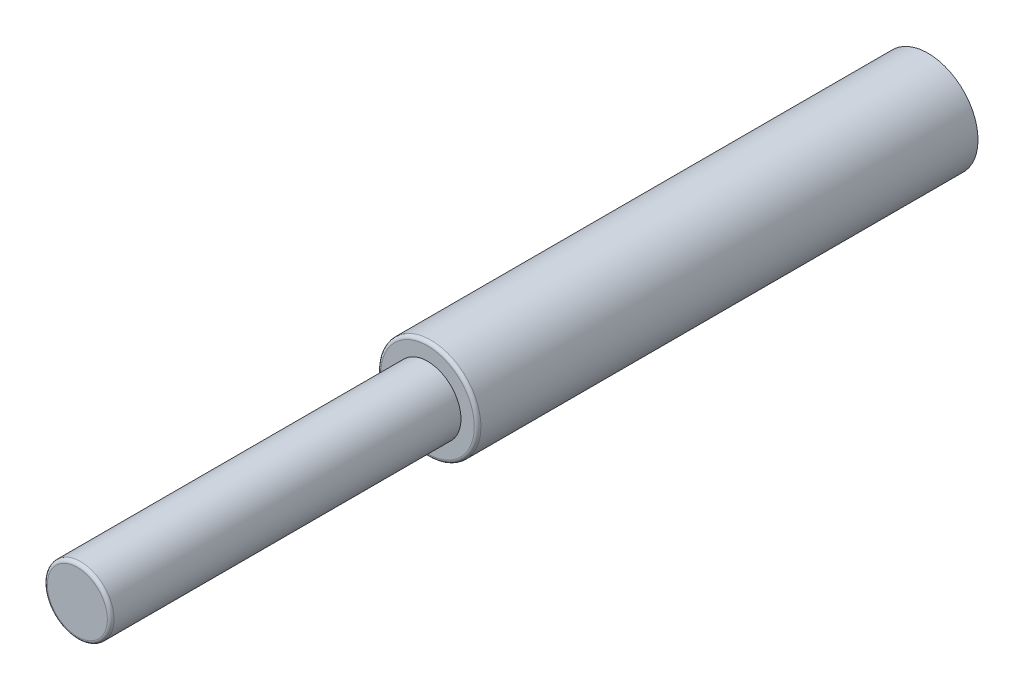
from build123d import *

# Parameters (mm, degrees)
SKETCH2_R           = 30
BOSS_EXTRUDE1_DEPTH = 300
SKETCH3_R           = 20
BOSS_EXTRUDE2_DEPTH = 210
FILLET1_R           = 2
FILLET2_R           = 2


with BuildPart() as part:
    # Sketch2 → Boss-Extrude1 (new body)
    with BuildSketch(Plane.XY):
        Circle(SKETCH2_R)
    extrude(amount=BOSS_EXTRUDE1_DEPTH)

    # Sketch3 → Boss-Extrude2 (add)
    with BuildSketch(Plane.XY.offset(300)):
        Circle(SKETCH3_R)
    extrude(amount=BOSS_EXTRUDE2_DEPTH)

    # Fillet1
    fillet1_edges = [part.edges().sort_by_distance(p)[0] for p in [
        (-20, 0, 510),
    ]]
    fillet(fillet1_edges, radius=FILLET1_R)

    # Fillet2
    fillet2_edges = [part.edges().sort_by_distance(p)[0] for p in [
        (-30, 0, 300),
    ]]
    fillet(fillet2_edges, radius=FILLET2_R)


solid = part.part
